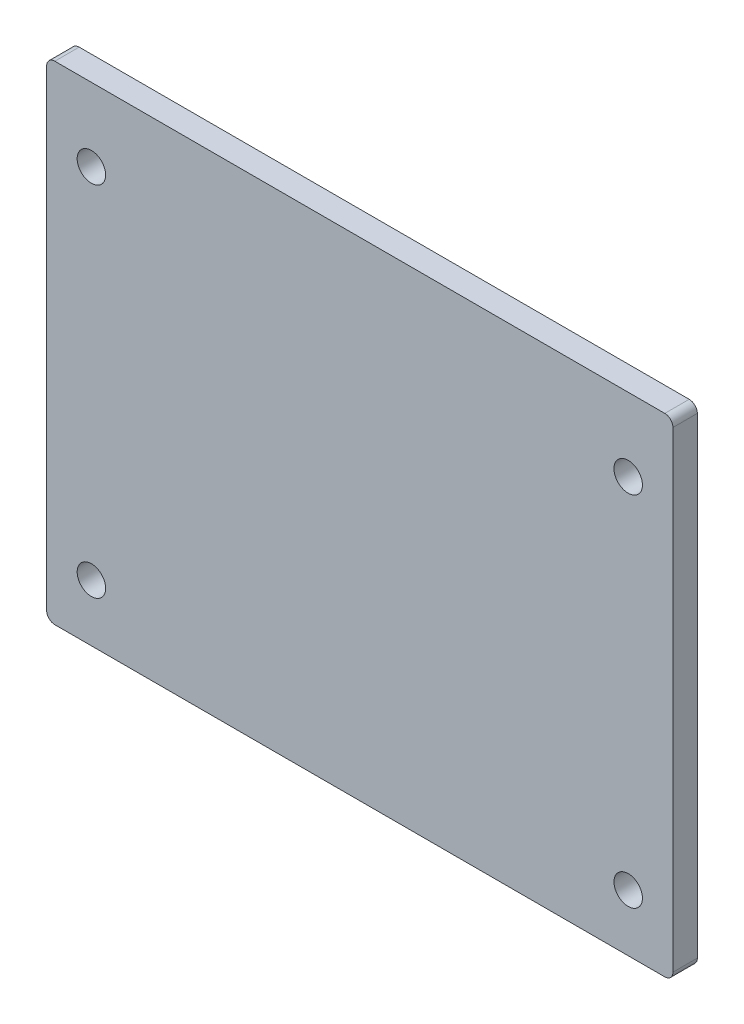
from build123d import *

# Parameters (mm, degrees)
SKETCH1_W           = 77
SKETCH1_H           = 60
SKETCH1_R           = 1.75
BOSS_EXTRUDE1_DEPTH = 3
FILLET1_R           = 1


with BuildPart() as part:
    # Sketch1 → Boss-Extrude1 (new body)
    with BuildSketch(Plane.XY):
        Rectangle(SKETCH1_W, SKETCH1_H)
        with Locations((33, -23)):
            Circle(SKETCH1_R, mode=Mode.SUBTRACT)
        with Locations((-33, -23)):
            Circle(SKETCH1_R, mode=Mode.SUBTRACT)
        with Locations((33, 21)):
            Circle(SKETCH1_R, mode=Mode.SUBTRACT)
        with Locations((-33, 21)):
            Circle(SKETCH1_R, mode=Mode.SUBTRACT)
    extrude(amount=BOSS_EXTRUDE1_DEPTH)

    # Fillet1
    fillet1_edges = [part.edges().sort_by_distance(p)[0] for p in [
        (38.5, -30, 1.5),
        (-38.5, -30, 1.5),
        (-38.5, 30, 1.5),
        (38.5, 30, 1.5),
    ]]
    fillet(fillet1_edges, radius=FILLET1_R)


solid = part.part
